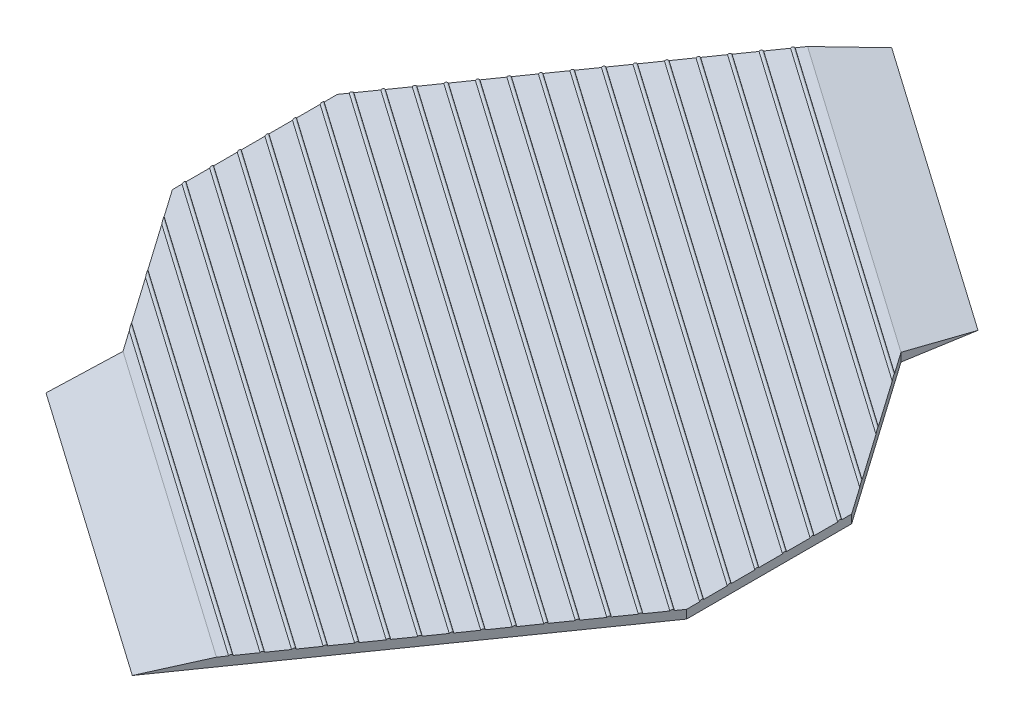
from build123d import *

# Parameters (mm, degrees)
EXTRUDE_1_DEPTH          = 90
EXTRUDE_2_DEPTH          = 90
CUT_EXTRUDE_1_DEPTH      = 7594.314402262
PATTERN_CIRCULAR_2_COUNT = 2
SKETCH_9_R               = 20
EXTRUDE_3_DEPTH          = 8000
PATTERN_LINEAR_1_COUNT   = 24
PATTERN_LINEAR_1_PITCH   = 240
SKETCH_10_W              = 14000
SKETCH_10_H              = 14000
CUT_EXTRUDE_2_DEPTH      = 8000


with BuildPart() as part:
    # 草图2 → 凸台-拉伸1 (new body)
    with BuildSketch(Plane(origin=(0, 0, 0), x_dir=(1, 0, 0), z_dir=(0, 1, 0))):
        Polygon((-2614.527838122, 2403), (1483.472161878, 2403), (2154.099194276, 1933.421896588), (3290, 311.187425036), (3290, -1438.325778405), (2614.527838122, -2403), (-1483.472161878, -2403), (-2154.099194276, -1933.421896588), (-3290, -311.187425036), (-3290, 1438.325778405), align=None)
    extrude(amount=EXTRUDE_1_DEPTH)



with BuildPart() as body_2:
    # 草图5 → 凸台-拉伸2 (new body)
    with BuildSketch(Plane(origin=(0, 90, 0), x_dir=(1, 0, 0), z_dir=(0, 1, 0))):
        Polygon((1236.45451391, -4371.092671119), (2614.527838122, -2403), (-1483.472161878, -2403), (-2154.099194276, -1933.421896588), (-2066.757561129, -2058.158675872), align=None)
        Polygon((869.365594645, -4895.349979464), (1236.45451391, -4371.092671119), (-2066.757561129, -2058.158675872), (-2183.477702067, -2757.726090133), align=None)
    extrude(amount=-EXTRUDE_2_DEPTH)

    # 草图6 → 切除-拉伸1 (cut, through all)
    with BuildSketch(Plane(origin=(2883.415195897, 0, 2018.989055956), x_dir=(0.573576436, 0, -0.819152044), z_dir=(0.819152044, 0, 0.573576436))):
        Polygon((-3511.388323525, 0), (-2871.005048511, 90), (-3511.388323525, 90), align=None)
    extrude(amount=-CUT_EXTRUDE_1_DEPTH, mode=Mode.SUBTRACT)


with BuildPart() as pattern_circular_2_1:
    # 阵列(圆周)2: pattern copy
    add(body_2.part.rotate(Axis((0, 0, 0), (0, 1, 0)), 1 * 360 / PATTERN_CIRCULAR_2_COUNT))


with BuildPart() as part_1:
    add(part.part)

    add(body_2.part)  # 凸台-拉伸3 merges body 2
    # 草图9 → 凸台-拉伸3 (add)
    with BuildSketch(Plane(origin=(2883.415195897, 0, 2018.989055956), x_dir=(0.573576436, 0, -0.819152044), z_dir=(0.819152044, 0, 0.573576436))):
        with Locations((-2761.005048511, 80.3)):
            Circle(SKETCH_9_R)
    extrude_3 = extrude(amount=-EXTRUDE_3_DEPTH)


    add(pattern_circular_2_1.part)  # 阵列(线性)1 merges 阵列(圆周)2_1
    # 阵列(线性)1: 凸台-拉伸3 ×24
    with Locations(*[Vector(0.573576436, 0, -0.819152044) * (i * PATTERN_LINEAR_1_PITCH) for i in range(1, PATTERN_LINEAR_1_COUNT)]):
        add(extrude_3)

    # 草图10 → 切除-拉伸2 (cut)
    with BuildSketch(Plane.XZ):
        Rectangle(SKETCH_10_W, SKETCH_10_H)
        Polygon((2066.757561129, -2058.158675872), (3290, -311.187425036), (3290, 1438.325778405), (869.365594645, 4895.349979464), (-2183.477702067, 2757.726090133), (-2066.757561129, 2058.158675872), (-3290, 311.187425036), (-3290, -1438.325778405), (-869.365594645, -4895.349979464), (2183.477702067, -2757.726090133), align=None, mode=Mode.SUBTRACT)
    extrude(amount=-CUT_EXTRUDE_2_DEPTH, mode=Mode.SUBTRACT)


solid = part_1.part
